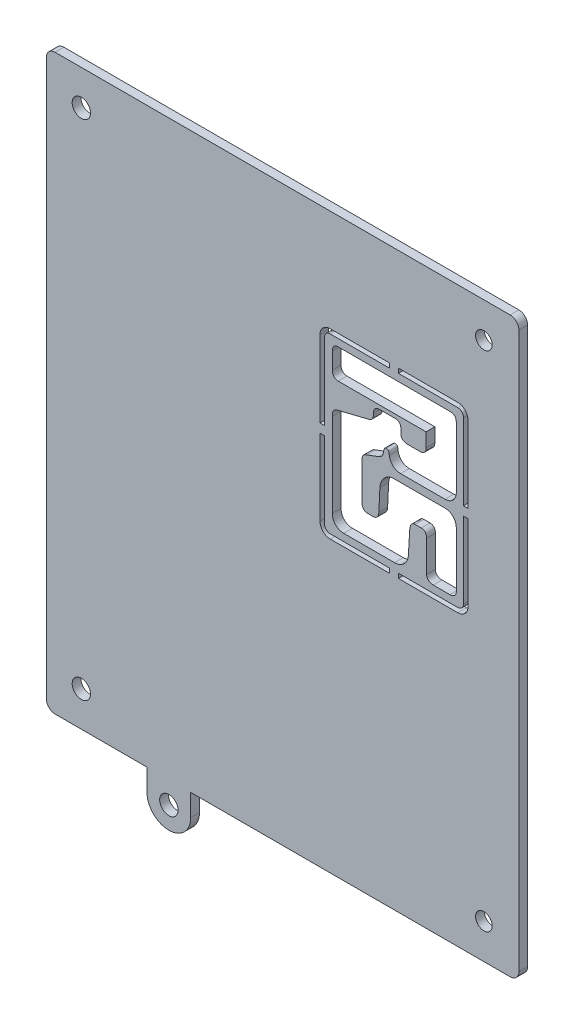
from build123d import *

# Parameters (mm, degrees)
SKETCH2_R           = 2.1
SKETCH2_R_2         = 1.9
BOSS_EXTRUDE1_DEPTH = 2
CUT_EXTRUDE2_DEPTH  = 3
FILLET1_R           = 2


with BuildPart() as part:
    # Sketch2 → Boss-Extrude1 (new body)
    with BuildSketch(Plane.XY):
        with BuildLine():
            Line((0.167188, 159.1806075), (0.167188, 28.18105))
            Line((0.167188, 28.18105), (23.16763175, 28.18105))
            Line((23.16763175, 28.18105), (23.16763175, 23.18105))
            ThreePointArc((23.16763175, 23.18105), (28.16763175, 18.18105), (33.16763175, 23.18105))
            Line((33.16763175, 23.18105), (33.16763175, 28.18105))
            Line((33.16763175, 28.18105), (108.16728925, 28.18105))
            Line((108.16728925, 28.18105), (108.16728925, 159.1806075))
            Line((108.16728925, 159.1806075), (0.167188, 159.1806075))
        make_face()
        with Locations((8.167632375, 151.180160625)):
            Circle(SKETCH2_R, mode=Mode.SUBTRACT)
        with Locations((100.1668405, 151.180160625)):
            Circle(SKETCH2_R_2, mode=Mode.SUBTRACT)
        with Locations((100.1668405, 36.181495)):
            Circle(SKETCH2_R_2, mode=Mode.SUBTRACT)
        with Locations((8.16763175, 36.181495)):
            Circle(SKETCH2_R, mode=Mode.SUBTRACT)
        with Locations((28.16763175, 23.18105)):
            Circle(SKETCH2_R, mode=Mode.SUBTRACT)
    extrude(amount=BOSS_EXTRUDE1_DEPTH)

    # Sketch8 → Cut-Extrude2 (cut, through all)
    with BuildSketch(Plane.XY.offset(2)):
        with BuildLine():
            Line((94.184318522, 95.295862027), (80.621874847, 95.295862027))
            Line((80.621874847, 95.295862027), (80.621874847, 94.261802095))
            Line((80.621874847, 94.261802095), (94.184318522, 94.261802095))
            add(Edge.make_bspline(
                [(94.184318522, 94.261802095), (95.482115127, 94.261802095), (96.537906215, 95.317875583), (96.537906215, 96.615953786)],
                knots=[0, 0, 0, 0, 1, 1, 1, 1], degree=3))
            Line((96.537906215, 96.615953786), (96.537906215, 114.046810125))
            Line((96.537906215, 114.046810125), (95.503845883, 114.046810125))
            Line((95.503845883, 114.046810125), (95.503845883, 96.615953786))
            add(Edge.make_bspline(
                [(95.503845883, 96.615953786), (95.503845883, 95.888104442), (94.911886267, 95.295862027), (94.184318522, 95.295862027)],
                knots=[0, 0, 0, 0, 1, 1, 1, 1], degree=3))
        make_face()
        with BuildLine():
            Line((65.053060385, 134.860079298), (78.599982491, 134.860079298))
            Line((78.599982491, 134.860079298), (78.599982491, 135.89413963))
            Line((78.599982491, 135.89413963), (65.053060385, 135.89413963))
            add(Edge.make_bspline(
                [(65.053060385, 135.89413963), (63.755264181, 135.89413963), (62.699473092, 134.837784143), (62.699473092, 133.53928194)],
                knots=[0, 0, 0, 0, 1, 1, 1, 1], degree=3))
            Line((62.699473092, 133.53928194), (62.699473092, 116.068632481))
            Line((62.699473092, 116.068632481), (63.733533024, 116.068632481))
            Line((63.733533024, 116.068632481), (63.733533024, 133.53928194))
            add(Edge.make_bspline(
                [(63.733533024, 133.53928194), (63.733533024, 134.267555283), (64.32549304, 134.860079298), (65.053060385, 134.860079298)],
                knots=[0, 0, 0, 0, 1, 1, 1, 1], degree=3))
        make_face()
        with BuildLine():
            Line((94.184346922, 135.89409683), (80.621902847, 135.89409683))
            Line((80.621902847, 135.89409683), (80.621902847, 134.860036498))
            Line((80.621902847, 134.860036498), (94.184346922, 134.860036498))
            add(Edge.make_bspline(
                [(94.184346922, 134.860036498), (94.911914267, 134.860036498), (95.503874283, 134.267512083), (95.503874283, 133.53923914)],
                knots=[0, 0, 0, 0, 1, 1, 1, 1], degree=3))
            Line((95.503874283, 133.53923914), (95.503874283, 116.068589681))
            Line((95.503874283, 116.068589681), (96.537934615, 116.068589681))
            Line((96.537934615, 116.068589681), (96.537934615, 133.53923914))
            add(Edge.make_bspline(
                [(96.537934615, 133.53923914), (96.537934615, 134.837740943), (95.482143127, 135.89409683), (94.184346922, 135.89409683)],
                knots=[0, 0, 0, 0, 1, 1, 1, 1], degree=3))
        make_face()
        with BuildLine():
            Line((78.600038891, 95.295862027), (65.053116785, 95.295862027))
            add(Edge.make_bspline(
                [(65.053116785, 95.295862027), (64.32554944, 95.295862027), (63.733589424, 95.888104442), (63.733589424, 96.615953786)],
                knots=[0, 0, 0, 0, 1, 1, 1, 1], degree=3))
            Line((63.733589424, 96.615953786), (63.733589424, 114.046810125))
            Line((63.733589424, 114.046810125), (62.699529492, 114.046810125))
            Line((62.699529492, 114.046810125), (62.699529492, 96.615953786))
            add(Edge.make_bspline(
                [(62.699529492, 96.615953786), (62.699529492, 95.317875583), (63.755320581, 94.261802095), (65.053116785, 94.261802095)],
                knots=[0, 0, 0, 0, 1, 1, 1, 1], degree=3))
            Line((65.053116785, 94.261802095), (78.600038891, 94.261802095))
            Line((78.600038891, 94.261802095), (78.600038891, 95.295862027))
        make_face()
        with BuildLine():
            Line((87.089083513, 105.476374066), (87.083856723, 98.282261654))
            add(Edge.make_bspline(
                [(87.083856723, 98.282261654), (87.083856723, 97.262312494), (87.918668254, 96.937757943), (88.568906953, 96.937757943)],
                knots=[0, 0, 0, 0, 1, 1, 1, 1], degree=3))
            add(Edge.make_bspline(
                [(88.568906953, 96.937757943), (88.741344608, 96.937757943), (91.959376972, 96.937080344), (92.371984947, 96.937080344)],
                knots=[0, 0, 0, 0, 1, 1, 1, 1], degree=3))
            add(Edge.make_bspline(
                [(92.371984947, 96.937080344), (93.022364846, 96.937080344), (93.857176377, 97.262340894), (93.857176377, 98.282290054)],
                knots=[0, 0, 0, 0, 1, 1, 1, 1], degree=3))
            Line((93.857176377, 98.282290054), (93.861838767, 110.856816905))
            add(Edge.make_bspline(
                [(93.861838767, 110.856816905), (93.861838767, 112.527145964), (92.609621272, 113.501234016), (91.264552762, 113.501234016)],
                knots=[0, 0, 0, 0, 1, 1, 1, 1], degree=3))
            add(Edge.make_bspline(
                [(91.264552762, 113.501234016), (90.574379742, 113.501234016), (80.309695872, 113.500556817), (79.596804097, 113.500556817)],
                knots=[0, 0, 0, 0, 1, 1, 1, 1], degree=3))
            add(Edge.make_bspline(
                [(79.596804097, 113.500556817), (77.88075513, 113.500556817), (76.581406528, 112.016211786), (76.396974897, 110.160745497)],
                knots=[0, 0, 0, 0, 1, 1, 1, 1], degree=3))
            Line((76.396974897, 110.160745497), (76.164000963, 105.105450007))
            add(Edge.make_bspline(
                [(76.164000963, 105.105450007), (76.118281055, 103.991380236), (75.515032261, 103.621105376), (74.772506946, 103.621105376)],
                knots=[0, 0, 0, 0, 1, 1, 1, 1], degree=3))
            Line((74.772506946, 103.621105376), (73.566009359, 103.622369774))
            add(Edge.make_bspline(
                [(73.566009359, 103.622369774), (72.772402146, 103.651861715), (72.29036751, 104.205298608), (72.29036751, 105.197589823)],
                knots=[0, 0, 0, 0, 1, 1, 1, 1], degree=3))
            Line((72.29036751, 105.197589823), (72.29036751, 113.546976324))
            add(Edge.make_bspline(
                [(72.29036751, 113.546976324), (72.29036751, 114.706343206), (72.846202799, 114.892186034), (73.356741778, 115.078734461)],
                knots=[0, 0, 0, 0, 1, 1, 1, 1], degree=3))
            Line((73.356741778, 115.078734461), (76.094009903, 116.098542421))
            add(Edge.make_bspline(
                [(76.094009903, 116.098542421), (76.650127591, 116.283820851), (77.161230969, 116.840503337), (77.206950877, 117.490177638)],
                knots=[0, 0, 0, 0, 1, 1, 1, 1], degree=3))
            add(Edge.make_bspline(
                [(77.206950877, 117.490177638), (77.3455218, 118.370709077), (77.438372814, 118.602977412), (77.85577838, 118.602977412)],
                knots=[0, 0, 0, 0, 1, 1, 1, 1], degree=3))
            add(Edge.make_bspline(
                [(77.85577838, 118.602977412), (78.413307264, 118.602977412), (78.459873971, 118.324989168), (78.551878187, 117.583028252)],
                knots=[0, 0, 0, 0, 1, 1, 1, 1], degree=3))
            add(Edge.make_bspline(
                [(78.551878187, 117.583028252), (78.691295909, 116.283820851), (79.711385868, 115.263730891), (81.102879885, 115.263730891)],
                knots=[0, 0, 0, 0, 1, 1, 1, 1], degree=3))
            Line((81.102879885, 115.263730891), (91.261730768, 115.263730891))
            add(Edge.make_bspline(
                [(91.261730768, 115.263730891), (92.607504476, 115.263730891), (93.859863171, 116.237395343), (93.859863171, 117.907583203)],
                knots=[0, 0, 0, 0, 1, 1, 1, 1], degree=3))
            Line((93.859863171, 117.907583203), (93.859863171, 131.731082356))
            add(Edge.make_bspline(
                [(93.859863171, 131.731082356), (93.859863171, 132.751595915), (93.349465392, 133.214721389), (92.374671742, 133.214721389)],
                knots=[0, 0, 0, 0, 1, 1, 1, 1], degree=3))
            Line((92.374671742, 133.214721389), (66.862680366, 133.214721389))
            add(Edge.make_bspline(
                [(66.862680366, 133.214721389), (65.842166807, 133.214721389), (65.517612256, 132.380615457), (65.517612256, 131.731082356)],
                knots=[0, 0, 0, 0, 1, 1, 1, 1], degree=3))
            add(Edge.make_bspline(
                [(65.517612256, 131.731082356), (65.517612256, 131.558644701), (65.516934657, 128.339906738), (65.516934657, 127.927298764)],
                knots=[0, 0, 0, 0, 1, 1, 1, 1], degree=3))
            add(Edge.make_bspline(
                [(65.516934657, 127.927298764), (65.516934657, 127.277483263), (65.842195207, 126.442812933), (66.862708766, 126.442812933)],
                knots=[0, 0, 0, 0, 1, 1, 1, 1], degree=3))
            Line((66.862708766, 126.442812933), (86.948565394, 126.442812933))
            Line((86.948565394, 126.442812933), (86.948565394, 123.288703641))
            add(Edge.make_bspline(
                [(86.948565394, 123.288703641), (86.948565394, 122.406761005), (86.484733922, 121.850643317), (85.649075593, 121.850643317)],
                knots=[0, 0, 0, 0, 1, 1, 1, 1], degree=3))
            Line((85.649075593, 121.850643317), (82.727375836, 121.850643317))
            add(Edge.make_bspline(
                [(82.727375836, 121.850643317), (81.937719816, 121.850643317), (81.1957589, 122.220212578), (81.1957589, 123.102860813)],
                knots=[0, 0, 0, 0, 1, 1, 1, 1], degree=3))
            Line((81.1957589, 123.102860813), (81.1957589, 124.031228956))
            add(Edge.make_bspline(
                [(81.1957589, 124.031228956), (81.1957589, 125.097038824), (80.778212135, 125.560870296), (79.85054959, 125.560870296)],
                knots=[0, 0, 0, 0, 1, 1, 1, 1], degree=3))
            Line((79.85054959, 125.560870296), (76.279316732, 125.560870296))
            add(Edge.make_bspline(
                [(76.279316732, 125.560870296), (75.351512988, 125.560870296), (74.933965823, 124.958327102), (74.933965823, 124.123515171)],
                knots=[0, 0, 0, 0, 1, 1, 1, 1], degree=3))
            add(Edge.make_bspline(
                [(74.933965823, 124.123515171), (74.933965823, 122.731880354), (74.470134751, 122.545472727), (73.63532282, 122.313768791)],
                knots=[0, 0, 0, 0, 1, 1, 1, 1], degree=3))
            Line((73.63532282, 122.313768791), (66.816988857, 120.64414573))
            add(Edge.make_bspline(
                [(66.816988857, 120.64414573), (65.702777886, 120.365592687), (65.516934657, 119.763049492), (65.516934657, 118.788820241)],
                knots=[0, 0, 0, 0, 1, 1, 1, 1], degree=3))
            Line((65.516934657, 118.788820241), (65.517612256, 99.585047848))
            add(Edge.make_bspline(
                [(65.517612256, 99.585047848), (65.517612256, 97.914718789), (66.77053495, 96.940630737), (68.114192263, 96.940630737)],
                knots=[0, 0, 0, 0, 1, 1, 1, 1], degree=3))
            Line((68.114192263, 96.940630737), (79.736785818, 96.940630737))
            add(Edge.make_bspline(
                [(79.736785818, 96.940630737), (81.267132757, 96.940630737), (82.797338496, 98.192848233), (82.890189511, 99.816610585)],
                knots=[0, 0, 0, 0, 1, 1, 1, 1], degree=3))
            Line((82.890189511, 99.816610585), (83.214744462, 105.151869915))
            add(Edge.make_bspline(
                [(83.214744462, 105.151869915), (83.261169969, 106.264810889), (83.725001041, 106.867918882), (84.421242049, 106.867918882)],
                knots=[0, 0, 0, 0, 1, 1, 1, 1], degree=3))
            Line((84.421242049, 106.867918882), (85.837006817, 106.867918882))
            add(Edge.make_bspline(
                [(85.837006817, 106.867918882), (86.486540318, 106.867918882), (87.089083513, 106.449807319), (87.089083513, 105.476374066)],
                knots=[0, 0, 0, 0, 1, 1, 1, 1], degree=3))
        make_face()
    extrude(amount=-CUT_EXTRUDE2_DEPTH, mode=Mode.SUBTRACT)

    # Fillet1
    fillet1_edges = [part.edges().sort_by_distance(p)[0] for p in [
        (108.16728925, 159.1806075, 1),
        (108.16728925, 28.18105, 1),
        (0.167188, 28.18105, 1),
        (0.167188, 159.1806075, 1),
    ]]
    fillet(fillet1_edges, radius=FILLET1_R)


solid = part.part
